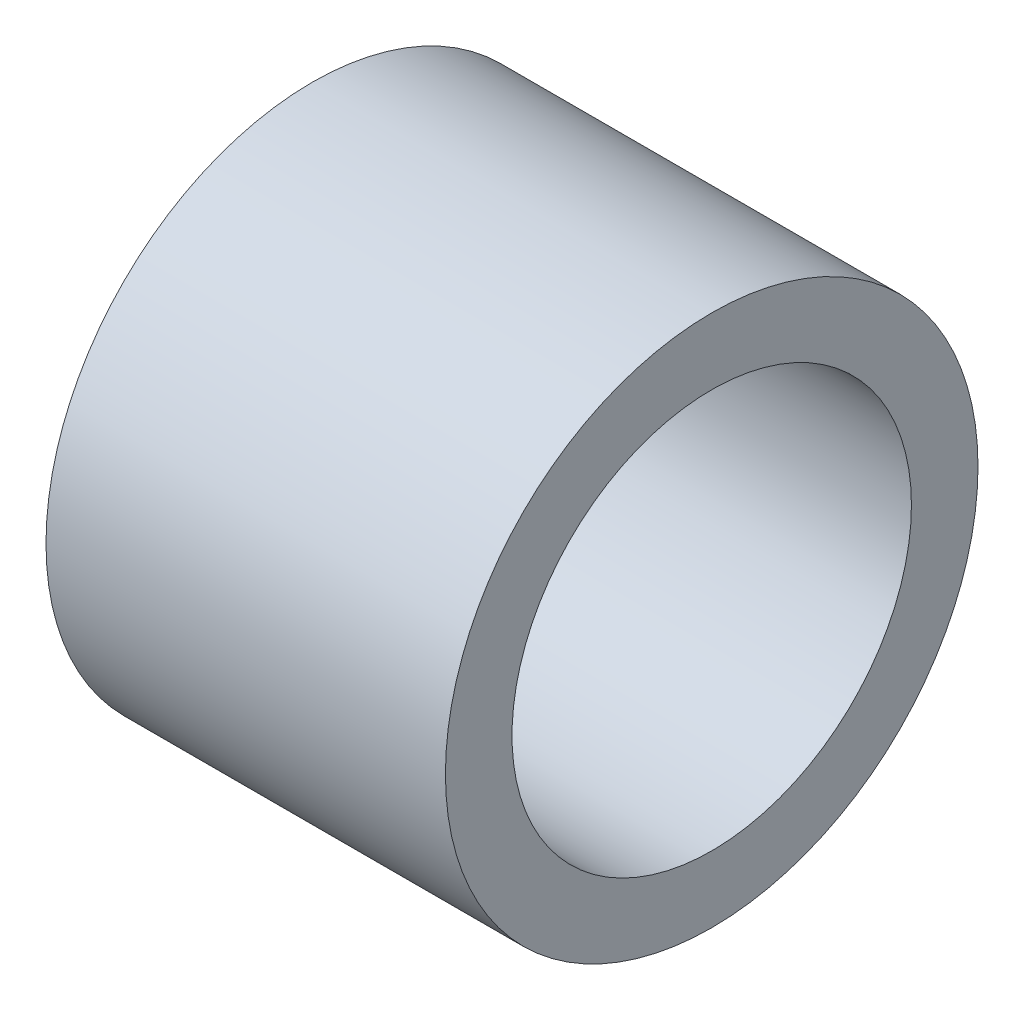
from build123d import *

# Parameters (mm, degrees)
SKETCH2_R           = 12.7
SKETCH2_R_2         = 9.525
BOSS_EXTRUDE1_DEPTH = 9.525


with BuildPart() as part:
    # Sketch2 → Boss-Extrude1 (new body, symmetric)
    with BuildSketch(Plane(origin=(0, 0, 0), x_dir=(0, 0, -1), z_dir=(1, 0, 0))):
        Circle(SKETCH2_R)
        Circle(SKETCH2_R_2, mode=Mode.SUBTRACT)
    extrude(amount=BOSS_EXTRUDE1_DEPTH, both=True)


solid = part.part
